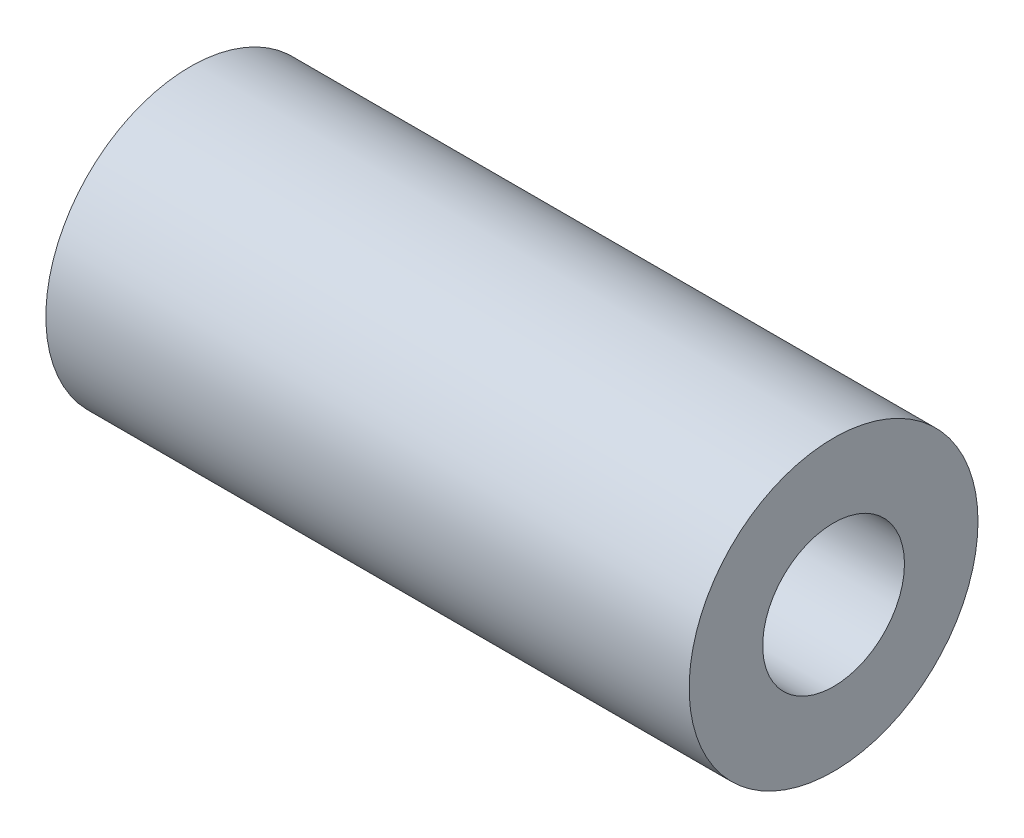
from build123d import *

# Parameters (mm, degrees)
SKETCH_1_R      = 5.5
SKETCH_1_R_2    = 2.7
EXTRUDE_1_DEPTH = 24.5


with BuildPart() as part:
    # 草图1 → 凸台-拉伸1 (new body)
    with BuildSketch(Plane(origin=(0, 0, 0), x_dir=(0, 0, -1), z_dir=(1, 0, 0))):
        Circle(SKETCH_1_R)
        Circle(SKETCH_1_R_2, mode=Mode.SUBTRACT)
    extrude(amount=EXTRUDE_1_DEPTH)


solid = part.part
